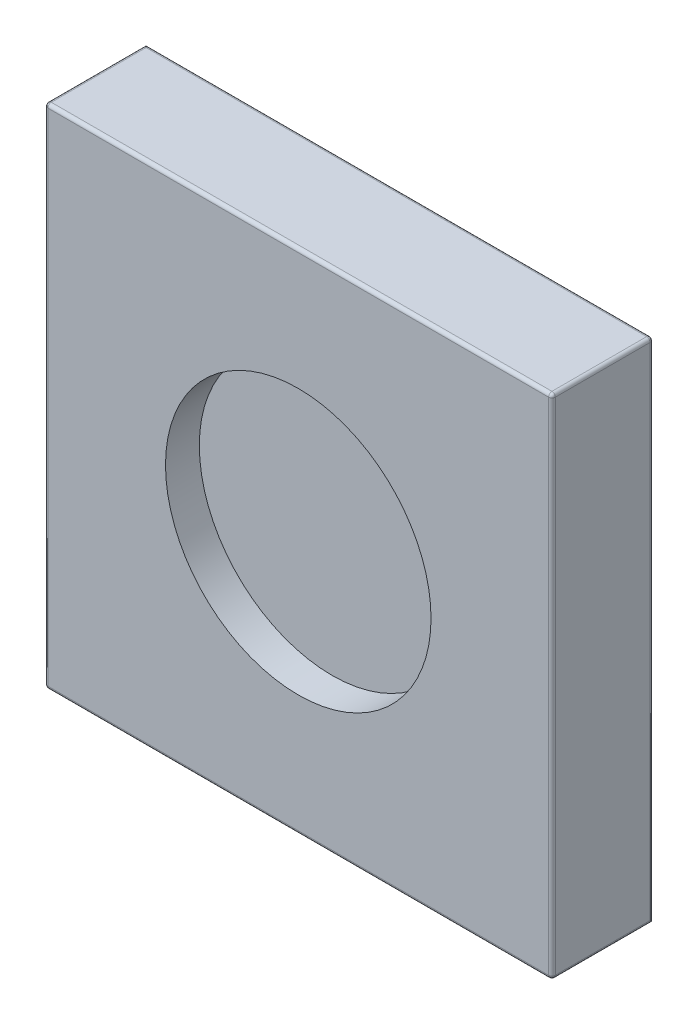
from build123d import *

# Parameters (mm, degrees)
SKETCH1_W           = 150
SKETCH1_H           = 150
BOSS_EXTRUDE1_DEPTH = 30
FILLET1_R           = 1
SKETCH2_R           = 39.25
CUT_EXTRUDE4_DEPTH  = 10


with BuildPart() as part:
    # Sketch1 → Boss-Extrude1 (new body)
    with BuildSketch(Plane.XY):
        Rectangle(SKETCH1_W, SKETCH1_H)
    extrude(amount=-BOSS_EXTRUDE1_DEPTH)

    # Fillet1
    fillet1_edges = [part.edges().sort_by_distance(p)[0] for p in [
        (75, -75, -15),
        (-75, -75, -15),
        (-75, 75, -15),
        (75, 0, -30),
        (0, 75, -30),
        (75, 75, -15),
        (0, -75, 0),
        (-75, 0, 0),
        (75, 0, 0),
        (0, 75, 0),
    ]]
    fillet(fillet1_edges, radius=FILLET1_R)

    # Sketch2 → Cut-Extrude4 (cut)
    with BuildSketch(Plane.XY):
        Circle(SKETCH2_R)
    extrude(amount=-CUT_EXTRUDE4_DEPTH, mode=Mode.SUBTRACT)


solid = part.part
